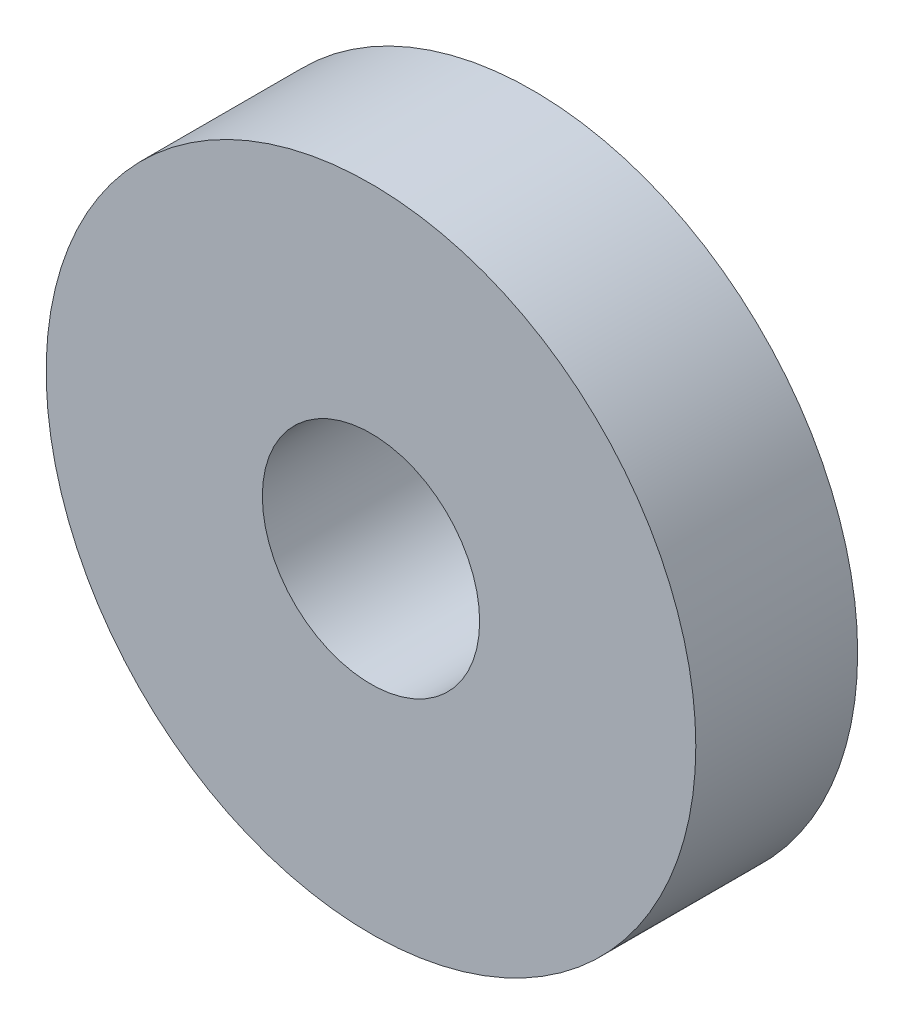
from build123d import *

# Parameters (mm, degrees)
SKETCH1_R      = 7.1374
SKETCH1_R_2    = 2.3876
EXTRUDE1_DEPTH = 3.556


with BuildPart() as part:
    # Sketch1 → Extrude1 (new body)
    with BuildSketch(Plane.XY):
        Circle(SKETCH1_R)
        Circle(SKETCH1_R_2, mode=Mode.SUBTRACT)
    extrude(amount=-EXTRUDE1_DEPTH)


solid = part.part
